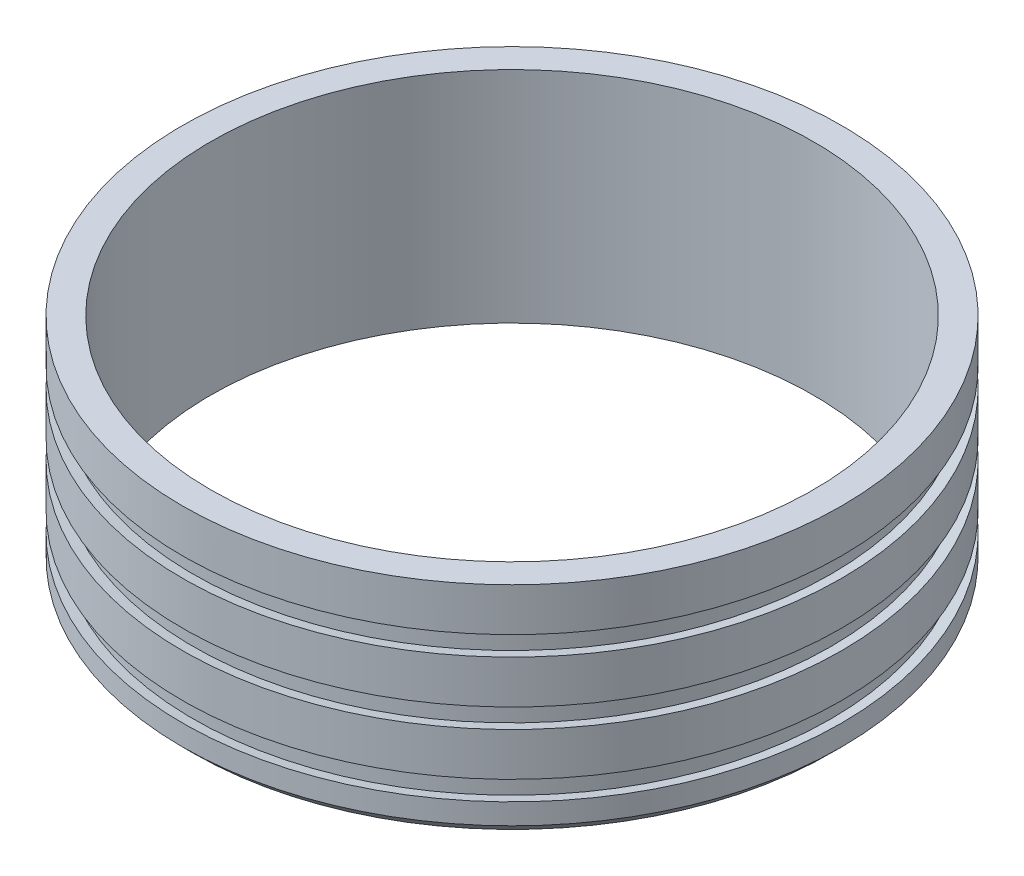
from build123d import *

# Parameters (mm, degrees)
SKETCH1_R           = 76.25
SKETCH1_R_2         = 69.75
BOSS_EXTRUDE1_DEPTH = 50.8
CHAMFER1_SIZE       = 2.5


with BuildPart() as part:
    # Sketch1 → Boss-Extrude1 (new body)
    with BuildSketch(Plane(origin=(0, 0, 0), x_dir=(1, 0, 0), z_dir=(0, 1, 0))):
        Circle(SKETCH1_R)
        Circle(SKETCH1_R_2, mode=Mode.SUBTRACT)
    extrude(amount=BOSS_EXTRUDE1_DEPTH)

    # Sketch2 → Cut-Revolve1 (revolve, cut)
    with BuildSketch(Plane.XY):
        Polygon((-76.25, 40.8), (-76.25, 36.3), (-73.75, 35.859182548), (-73.75, 41.240817452), align=None)
        Polygon((-73.75, 26.740817452), (-73.75, 21.359182548), (-76.25, 21.8), (-76.25, 26.3), align=None)
        Polygon((-73.75, 12.240817452), (-73.75, 6.859182548), (-76.25, 7.3), (-76.25, 11.8), align=None)
    revolve(axis=Axis((0, 0, 0), (0, 1, 0)), mode=Mode.SUBTRACT)

    # Chamfer1
    chamfer1_edges = [part.edges().sort_by_distance(p)[0] for p in [
        (-76.25, 0, 0),
    ]]
    chamfer(chamfer1_edges, length=CHAMFER1_SIZE)


solid = part.part
